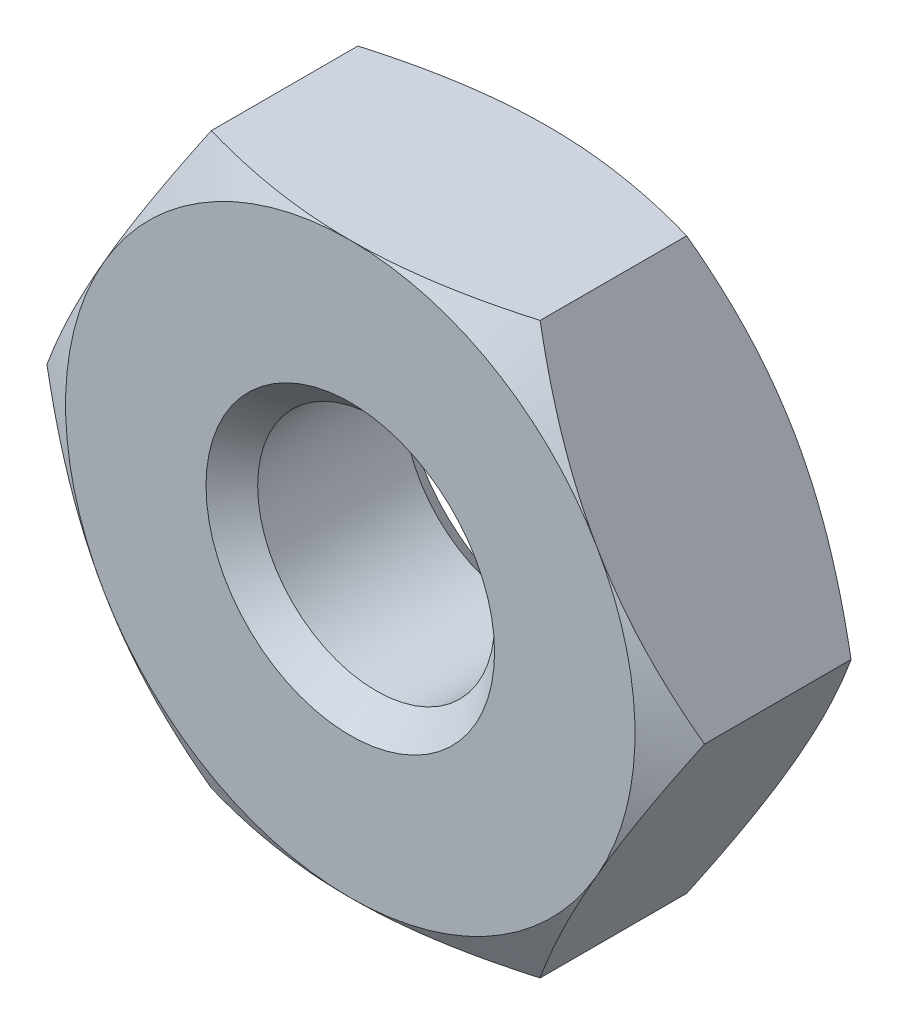
from build123d import *

# Parameters (mm, degrees)
BOSS_EXTRUDE1_DEPTH = 1.651


with BuildPart() as part:
    # Sketch1 → Boss-Extrude1 (new body, symmetric)
    with BuildSketch(Plane(origin=(0, 1.651, 0), x_dir=(-1, 0, 0), z_dir=(0, 0, -1))):
        Polygon((2.749630657, 3.1115), (-2.749630657, 3.1115), (-5.499261314, -1.651), (-2.749630657, -6.4135), (2.749630657, -6.4135), (5.499261314, -1.651), align=None)
    extrude(amount=BOSS_EXTRUDE1_DEPTH, both=True)

    # Sketch2 → Cut-Revolve1 (revolve, cut)
    with BuildSketch(Plane(origin=(0, 0, 0), x_dir=(-1, 0, 0), z_dir=(0, 1, 0))):
        Polygon((-5.499261314, -1.225630657), (-5.499261314, -1.651), (-4.7625, -1.651), align=None)
    cut_revolve1 = revolve(axis=Axis((0, 0, 0), (0, 0, -1)), mode=Mode.SUBTRACT)

    # Sketch4 → Cut-Revolve3 (revolve, cut)
    with BuildSketch(Plane(origin=(0, 0, 0), x_dir=(1, 0, 0), z_dir=(0, 1, 0))):
        Polygon((2.413, 1.651), (0, 1.651), (0, -1.2192), (1.9812, -1.2192), (1.9812, 1.2192), align=None)
    cut_revolve3 = revolve(axis=Axis((0, 0, -1.651), (0, 0, 1)), mode=Mode.SUBTRACT)

    # Mirror1: Cut-Revolve1, Cut-Revolve3 across plane
    add(cut_revolve1.mirror(Plane.XY), mode=Mode.SUBTRACT)
    add(cut_revolve3.mirror(Plane.XY), mode=Mode.SUBTRACT)


solid = part.part
